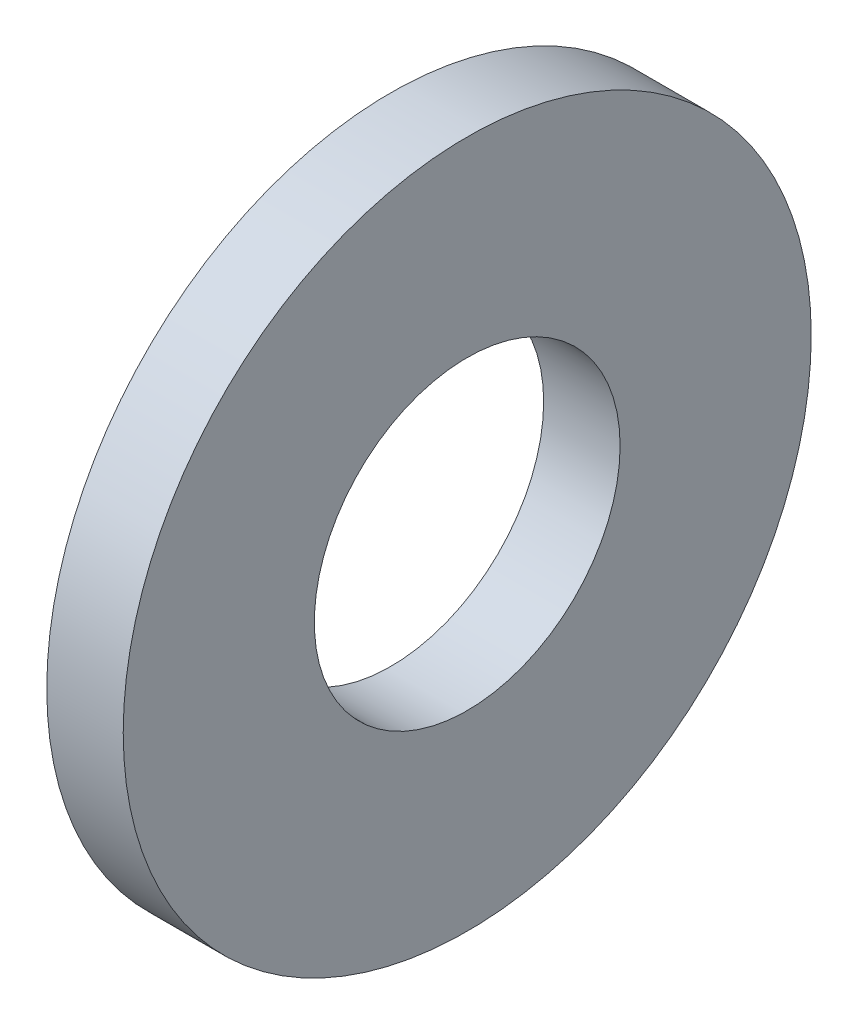
from build123d import *

# Parameters (mm, degrees)
SKETCH1_R           = 9
BOSS_EXTRUDE1_DEPTH = 2
SKETCH2_R           = 4
CUT_EXTRUDE1_DEPTH  = 3


with BuildPart() as part:
    # Sketch1 → Boss-Extrude1 (new body)
    with BuildSketch(Plane(origin=(0, 0, 0), x_dir=(0, 0, -1), z_dir=(1, 0, 0))):
        Circle(SKETCH1_R)
    extrude(amount=BOSS_EXTRUDE1_DEPTH)

    # Sketch2 → Cut-Extrude1 (cut, through all)
    with BuildSketch(Plane(origin=(2, 0, 0), x_dir=(0, 0, -1), z_dir=(1, 0, 0))):
        Circle(SKETCH2_R)
    extrude(amount=-CUT_EXTRUDE1_DEPTH, mode=Mode.SUBTRACT)


solid = part.part
